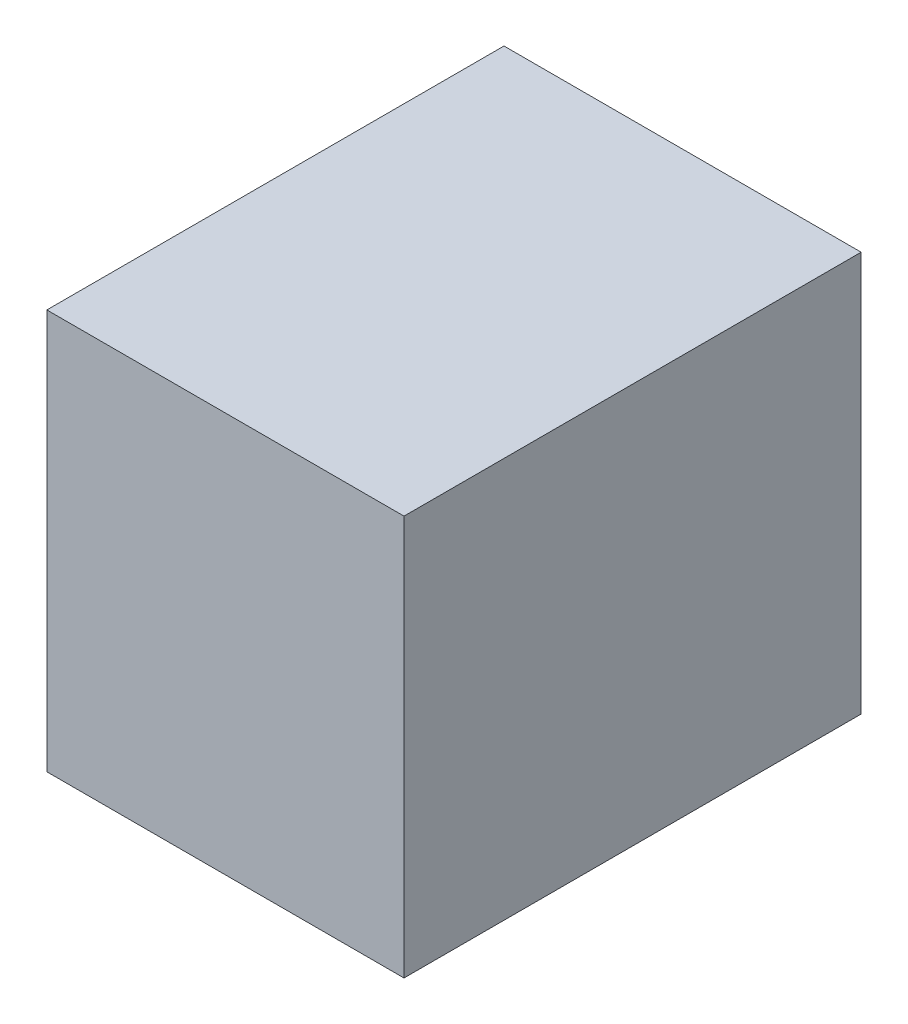
from build123d import *

# Parameters (mm, degrees)
SKETCH1_W           = 320
SKETCH1_H           = 280
BOSS_EXTRUDE1_DEPTH = 250


with BuildPart() as part:
    # Sketch1 → Boss-Extrude1 (new body)
    with BuildSketch(Plane(origin=(0, 0, 0), x_dir=(0, 0, -1), z_dir=(1, 0, 0))):
        Rectangle(SKETCH1_W, SKETCH1_H)
    extrude(amount=BOSS_EXTRUDE1_DEPTH)


solid = part.part
